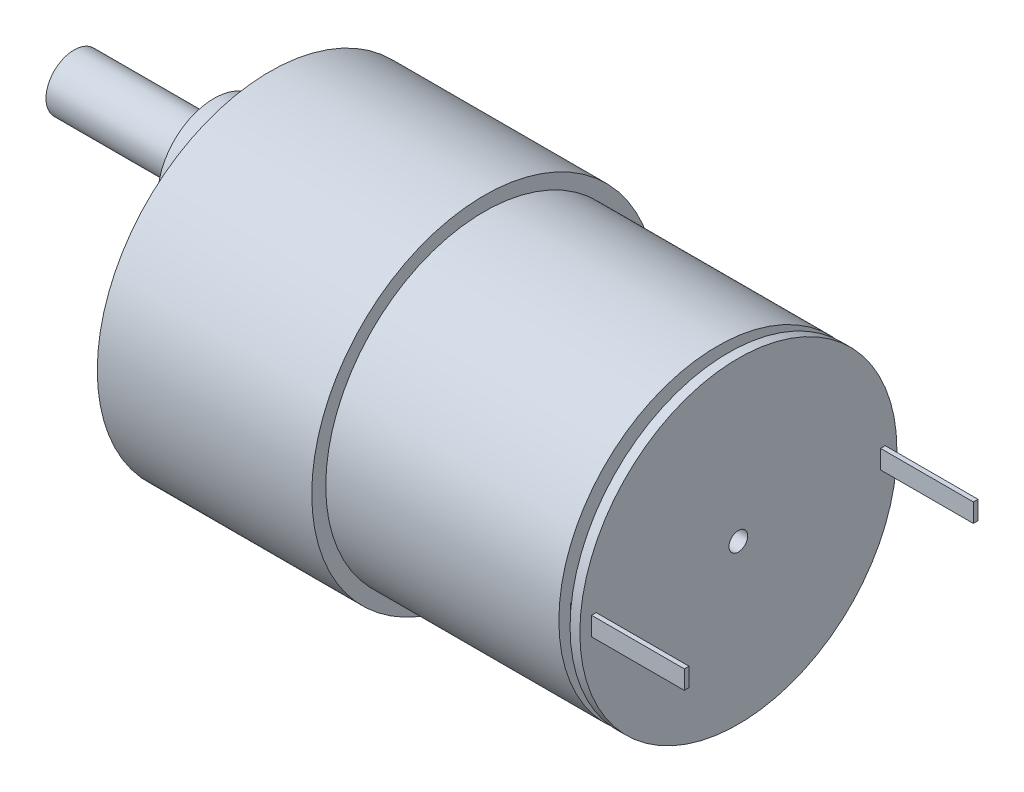
from build123d import *

# Parameters (mm, degrees)
SKETCH1_R                      = 17
BOSS_EXTRUDE1_DEPTH            = 1.05
SKETCH2_W                      = 0.5
SKETCH2_H                      = 2
POLES_DEPTH                    = 1.2
POLES_DEPTH_BACK               = 11
SKETCH3_R                      = 1.5
BOSS_EXTRUDE3_DEPTH            = 1.2
SKETCH5_R                      = 17
BOSS_EXTRUDE5_DEPTH            = 25
SKETCH6_R                      = 18.5
REDUCTUR_DEPTH                 = 21.5
SKETCH35_R                     = 18.5
ENDPLATE_DEPTH                 = 1.5
SKETCH36_R                     = 6
BOSS_EXTRUDE25_DEPTH           = 6
F_3_1_3_1_DIAMETER_HOLE1_D     = 6
F_3_1_3_1_DIAMETER_HOLE1_DEPTH = 2.2
F_2_0_2_DIAMETER_HOLE1_D       = 2
F_2_0_2_DIAMETER_HOLE1_DEPTH   = 2.25
F_3_0MM_1_D                    = 3
F_3_0MM_1_DEPTH                = 7.5
F_3_0MM_1_TIP                  = 0.901290929
SKETCH_1_R                     = 3
EXTRUDE_1_DEPTH                = 21


with BuildPart() as part:
    # Sketch1 → Boss-Extrude1 (new body)
    with BuildSketch(Plane(origin=(41.25, 0, 0), x_dir=(0, 0, -1), z_dir=(1, 0, 0))):
        Circle(SKETCH1_R)
    extrude(amount=-BOSS_EXTRUDE1_DEPTH)

    # Sketch2 → Poles (add, two sides)
    with BuildSketch(Plane.ZY.offset(-40.2)) as poles_sk:
        with Locations((15.5, 0)):
            Rectangle(SKETCH2_W, SKETCH2_H)
        with Locations((-15.5, 0)):
            Rectangle(SKETCH2_W, SKETCH2_H)
    extrude(amount=POLES_DEPTH)
    extrude(poles_sk.sketch, amount=-POLES_DEPTH_BACK)

    # Sketch3 → Boss-Extrude3 (add)
    with BuildSketch(Plane.ZY.offset(-40.2)):
        Circle(SKETCH3_R)
    extrude(amount=BOSS_EXTRUDE3_DEPTH)

    # Sketch5 → Boss-Extrude5 (add)
    with BuildSketch(Plane(origin=(39, 0, 0), x_dir=(0, 0, -1), z_dir=(1, 0, 0))):
        Circle(SKETCH5_R)
    extrude(amount=-BOSS_EXTRUDE5_DEPTH)

    # Sketch6 → Reductur (add)
    with BuildSketch(Plane(origin=(14, 0, 0), x_dir=(0, 0, -1), z_dir=(1, 0, 0))):
        Circle(SKETCH6_R)
    extrude(amount=-REDUCTUR_DEPTH)

    # Sketch35 → Endplate (add)
    with BuildSketch(Plane.ZY.offset(7.5)):
        Circle(SKETCH35_R)
    extrude(amount=ENDPLATE_DEPTH)

    # Sketch36 → Boss-Extrude25 (add)
    with BuildSketch(Plane.ZY.offset(9)):
        with Locations((0, 7)):
            Circle(SKETCH36_R)
    extrude(amount=BOSS_EXTRUDE25_DEPTH)

    # Ø3.1 (3.1) Diameter Hole1
    with Locations(Plane.ZY.offset(15)):
        with Locations((0, 7)):
            Hole(F_3_1_3_1_DIAMETER_HOLE1_D / 2, depth=F_3_1_3_1_DIAMETER_HOLE1_DEPTH)

    # Ø2.0 (2) Diameter Hole1
    with Locations(Plane(origin=(41.25, 0, 0), x_dir=(0, 0, -1), z_dir=(1, 0, 0))):
        with Locations((0, 0)):
            Hole(F_2_0_2_DIAMETER_HOLE1_D / 2, depth=F_2_0_2_DIAMETER_HOLE1_DEPTH)

    # Ø3.0mm 定位孔1
    with Locations(Plane(origin=(-9, 0, -15.5), x_dir=(0, 0, -1), z_dir=(-1, 0, 0))):
        with Locations((0, 0), (-7.75, -13.423393759), (-23.50507477, -13.272858695), (-31, 0), (-23.25, 13.423393759), (-7.75, 13.423393759)):
            Hole(F_3_0MM_1_D / 2, depth=F_3_0MM_1_DEPTH)
            with Locations((0, 0, -(F_3_0MM_1_DEPTH + F_3_0MM_1_TIP / 2))):  # 118° drill point
                Cone(0, F_3_0MM_1_D / 2, F_3_0MM_1_TIP, mode=Mode.SUBTRACT)

    # 草圖1 → 填料-伸長1 (add)
    with BuildSketch(Plane.ZY.offset(9)):
        with Locations((0, 7)):
            Circle(SKETCH_1_R)
    extrude(amount=EXTRUDE_1_DEPTH)


solid = part.part
